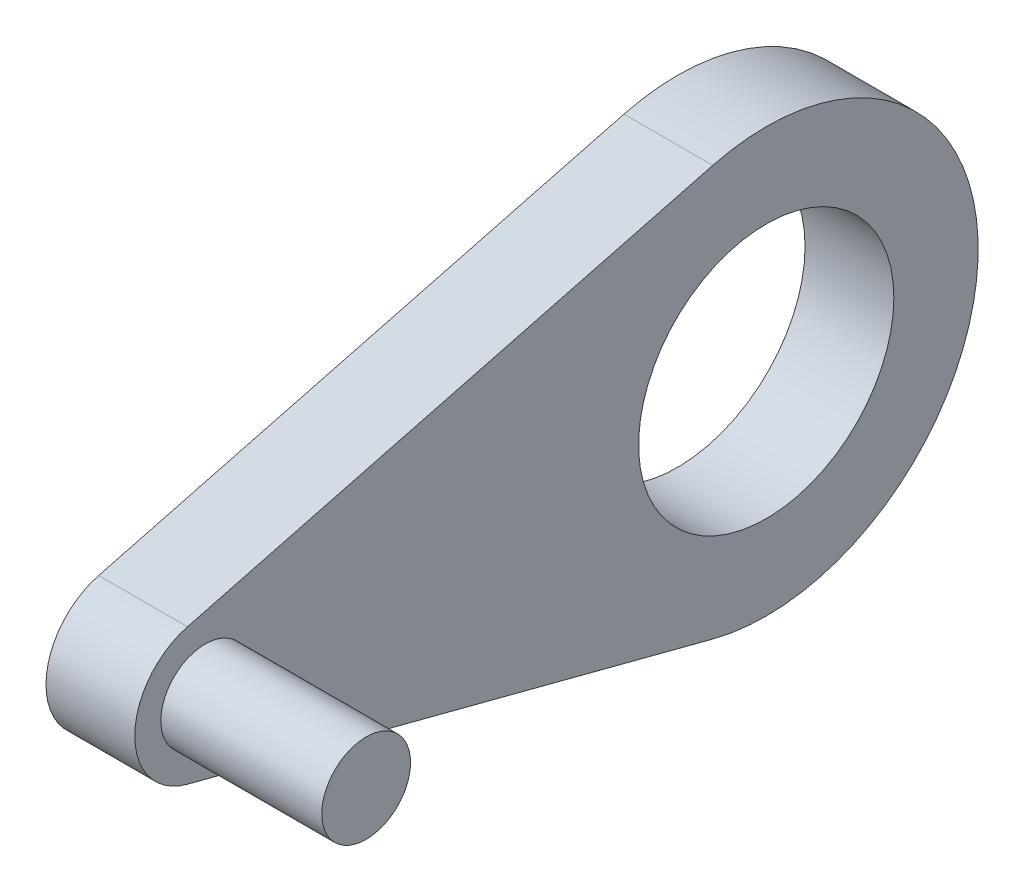
from build123d import *

# Parameters (mm, degrees)
BOSS_EXTRUDE1_DEPTH = 16
SKETCH2_R           = 8
BOSS_EXTRUDE2_DEPTH = 29
SKETCH3_R           = 23
CUT_EXTRUDE1_DEPTH  = 16


with BuildPart() as part:
    # Sketch1 → Boss-Extrude1 (new body)
    with BuildSketch(Plane(origin=(0, 0, 0), x_dir=(0, 0, -1), z_dir=(1, 0, 0))):
        with BuildLine():
            Line((-3.203264095, 12.289389698), (91.464985163, 36.964935941))
            ThreePointArc((91.464985163, 36.964935941), (139.3, 0), (91.464985163, -36.964935941))
            Line((91.464985163, -36.964935941), (-3.203264095, -12.289389698))
            ThreePointArc((-3.203264095, -12.289389698), (-12.7, 0), (-3.203264095, 12.289389698))
        make_face()
    extrude(amount=-BOSS_EXTRUDE1_DEPTH)

    # Sketch2 → Boss-Extrude2 (add)
    with BuildSketch(Plane(origin=(0, 0, 0), x_dir=(0, 0, -1), z_dir=(1, 0, 0))):
        Circle(SKETCH2_R)
    extrude(amount=BOSS_EXTRUDE2_DEPTH)

    # Sketch3 → Cut-Extrude1 (cut)
    with BuildSketch(Plane(origin=(0, 0, 0), x_dir=(0, 0, -1), z_dir=(1, 0, 0))):
        with Locations((101.1, 0)):
            Circle(SKETCH3_R)
    extrude(amount=-CUT_EXTRUDE1_DEPTH, mode=Mode.SUBTRACT)


solid = part.part
